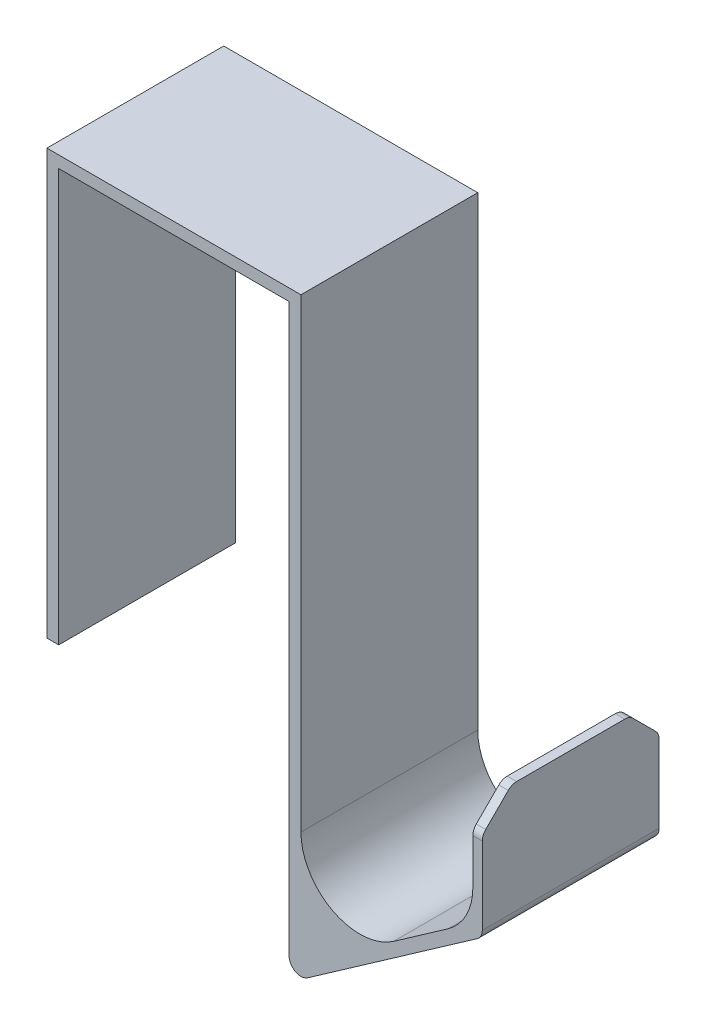
from build123d import *

# Parameters (mm, degrees)
BOSS_EXTRU_1_DEPTH = 30
CONG_1_R           = 10
CHANFREIN1_SIZE    = 5
CONG_2_R           = 2


with BuildPart() as part:
    # Esquisse1 → Boss.-Extru.1 (new body)
    with BuildSketch(Plane.XY):
        Polygon((-19.55, 43.689057372), (-19.55, 113.689057372), (19.55, 113.689057372), (19.55, 13.689057372), (52.316081772, 36.632114826), (52.316081772, 56.632114826), (50.716081772, 56.632114826), (50.716081772, 37.953331942), (21.55, 17.531021626), (21.55, 115.689057372), (-21.55, 115.689057372), (-21.55, 43.689057372), align=None)
    extrude(amount=BOSS_EXTRU_1_DEPTH)

    # Congé1
    cong_1_edges = [part.edges().sort_by_distance(p)[0] for p in [
        (21.55, 17.531021626, 15),
        (50.716081772, 37.953331942, 15),
    ]]
    fillet(cong_1_edges, radius=CONG_1_R)

    # Chanfrein1
    chanfrein1_edges = [part.edges().sort_by_distance(p)[0] for p in [
        (51.516081772, 56.632114826, 0),
        (51.516081772, 56.632114826, 30),
    ]]
    chamfer(chanfrein1_edges, length=CHANFREIN1_SIZE)

    # Congé2
    cong_2_edges = [part.edges().sort_by_distance(p)[0] for p in [
        (52.316081772, 36.632114826, 15),
        (19.55, 13.689057372, 15),
        (51.516081772, 56.632114826, 25),
        (51.516081772, 56.632114826, 5),
        (51.516081772, 51.632114826, 0),
        (51.516081772, 51.632114826, 30),
    ]]
    fillet(cong_2_edges, radius=CONG_2_R)


solid = part.part
